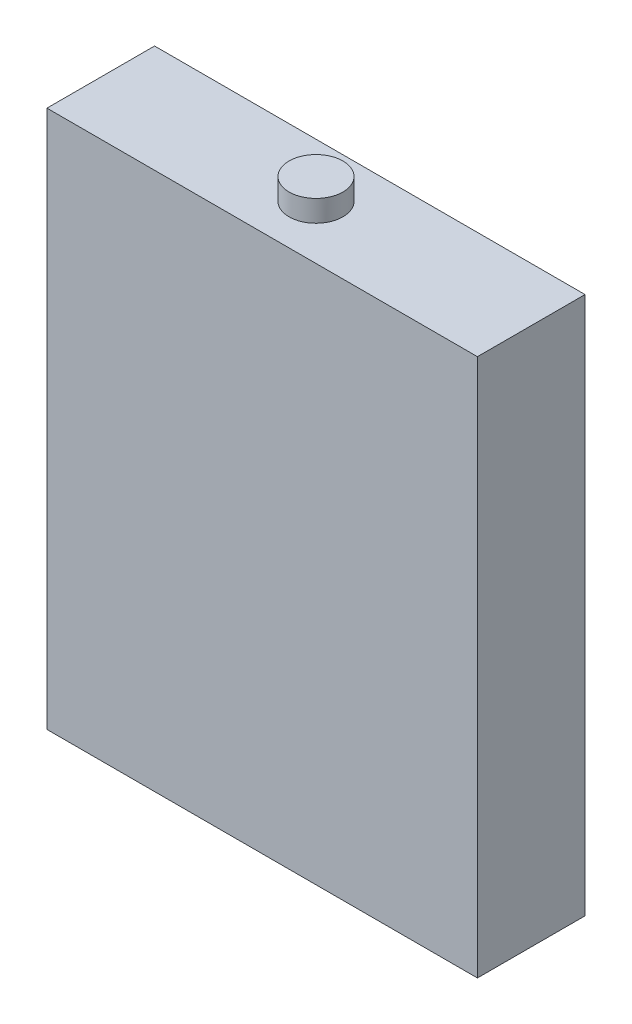
from build123d import *

# Parameters (mm, degrees)
SKETCH2_W           = 40
SKETCH2_H           = 10
BOSS_EXTRUDE1_DEPTH = 50
SKETCH3_R           = 2.5
BOSS_EXTRUDE2_DEPTH = 2


with BuildPart() as part:
    # Sketch2 → Boss-Extrude1 (new body)
    with BuildSketch(Plane(origin=(0, 0, 0), x_dir=(1, 0, 0), z_dir=(0, 1, 0))):
        Rectangle(SKETCH2_W, SKETCH2_H)
    extrude(amount=BOSS_EXTRUDE1_DEPTH)

    # Sketch3 → Boss-Extrude2 (add)
    with BuildSketch(Plane(origin=(0, 50, 0), x_dir=(1, 0, 0), z_dir=(0, 1, 0))):
        Circle(SKETCH3_R)
    extrude(amount=BOSS_EXTRUDE2_DEPTH)


solid = part.part
